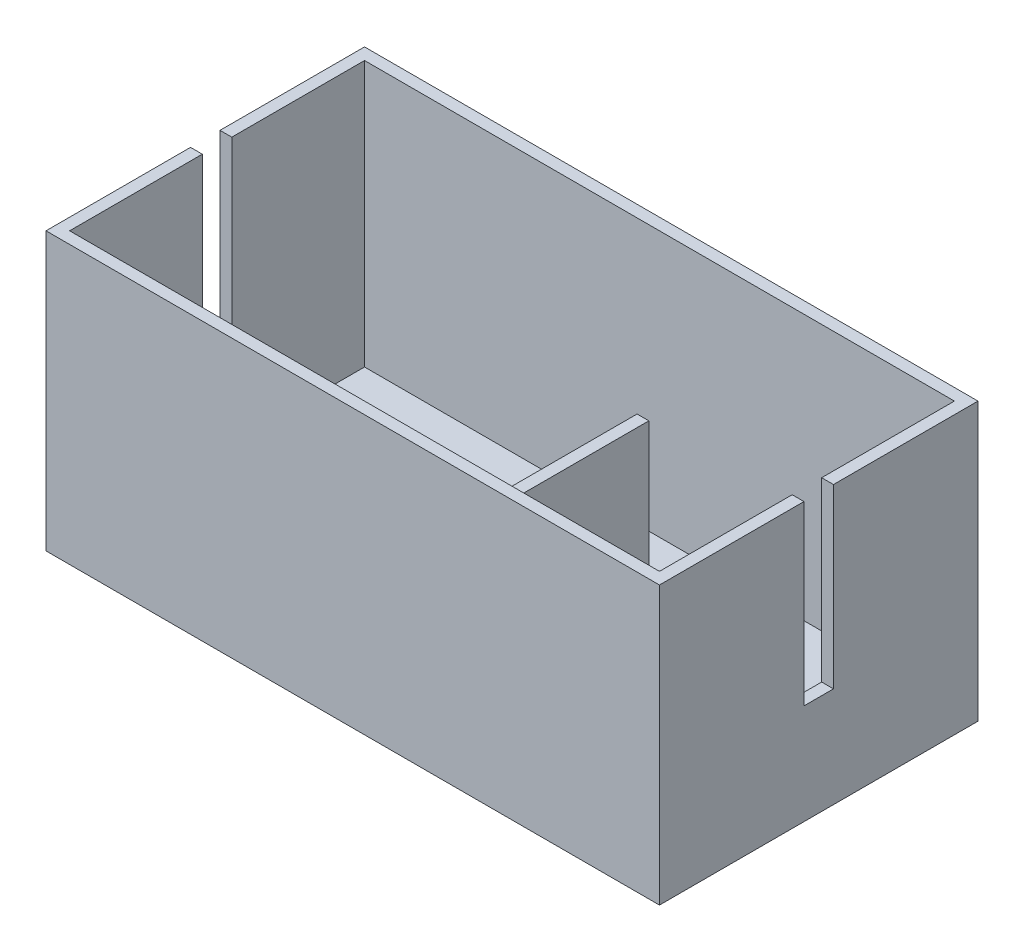
from build123d import *

# Parameters (mm, degrees)
SKETCH1_W           = 104
SKETCH1_H           = 54
SKETCH1_W_2         = 100
SKETCH1_H_2         = 50
BOSS_EXTRUDE1_DEPTH = 45
SKETCH2_W           = 104
SKETCH2_H           = 54
BOSS_EXTRUDE2_DEPTH = 2
SKETCH3_W           = 2
SKETCH3_H           = 5
CUT_EXTRUDE1_DEPTH  = 30
SKETCH4_W           = 2
SKETCH4_H           = 26.201240847
BOSS_EXTRUDE3_DEPTH = 40


with BuildPart() as part:
    # Sketch1 → Boss-Extrude1 (new body)
    with BuildSketch(Plane(origin=(0, 0, 0), x_dir=(1, 0, 0), z_dir=(0, 1, 0))):
        Rectangle(SKETCH1_W, SKETCH1_H)
        Rectangle(SKETCH1_W_2, SKETCH1_H_2, mode=Mode.SUBTRACT)
    extrude(amount=BOSS_EXTRUDE1_DEPTH)

    # Sketch2 → Boss-Extrude2 (add)
    with BuildSketch(Plane(origin=(0, 0, 0), x_dir=(1, 0, 0), z_dir=(0, 1, 0))):
        Rectangle(SKETCH2_W, SKETCH2_H)
    extrude(amount=-BOSS_EXTRUDE2_DEPTH)

    # Sketch3 → Cut-Extrude1 (cut)
    with BuildSketch(Plane(origin=(0, 45, 0), x_dir=(1, 0, 0), z_dir=(0, 1, 0))):
        with Locations((51, 0)):
            Rectangle(SKETCH3_W, SKETCH3_H)
        with Locations((-51, 0)):
            Rectangle(SKETCH3_W, SKETCH3_H)
    extrude(amount=-CUT_EXTRUDE1_DEPTH, mode=Mode.SUBTRACT)

    # Sketch4 → Boss-Extrude3 (add)
    with BuildSketch(Plane(origin=(0, 0, 0), x_dir=(1, 0, 0), z_dir=(0, 1, 0))):
        with Locations((21, -11.899379576)):
            Rectangle(SKETCH4_W, SKETCH4_H)
    extrude(amount=BOSS_EXTRUDE3_DEPTH)


solid = part.part
